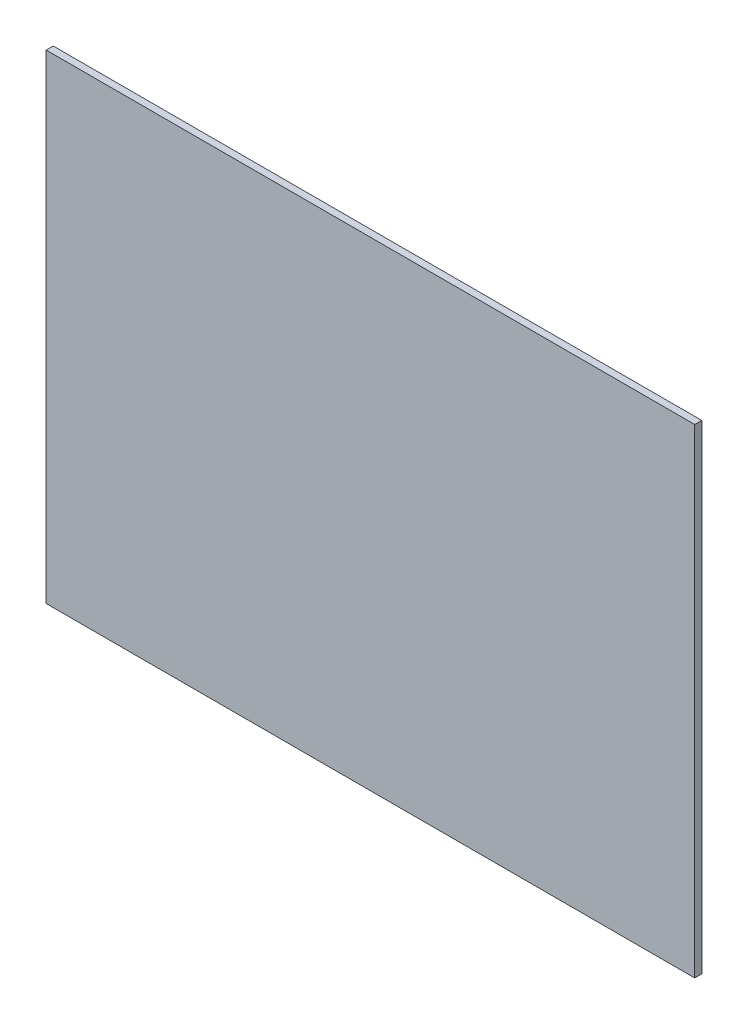
from build123d import *

# Parameters (mm, degrees)
SKETCH1_W           = 584.2
SKETCH1_H           = 431.8
BOSS_EXTRUDE1_DEPTH = 6.35


with BuildPart() as part:
    # Sketch1 → Boss-Extrude1 (new body)
    with BuildSketch(Plane.XY):
        Rectangle(SKETCH1_W, SKETCH1_H)
    extrude(amount=BOSS_EXTRUDE1_DEPTH)


solid = part.part
